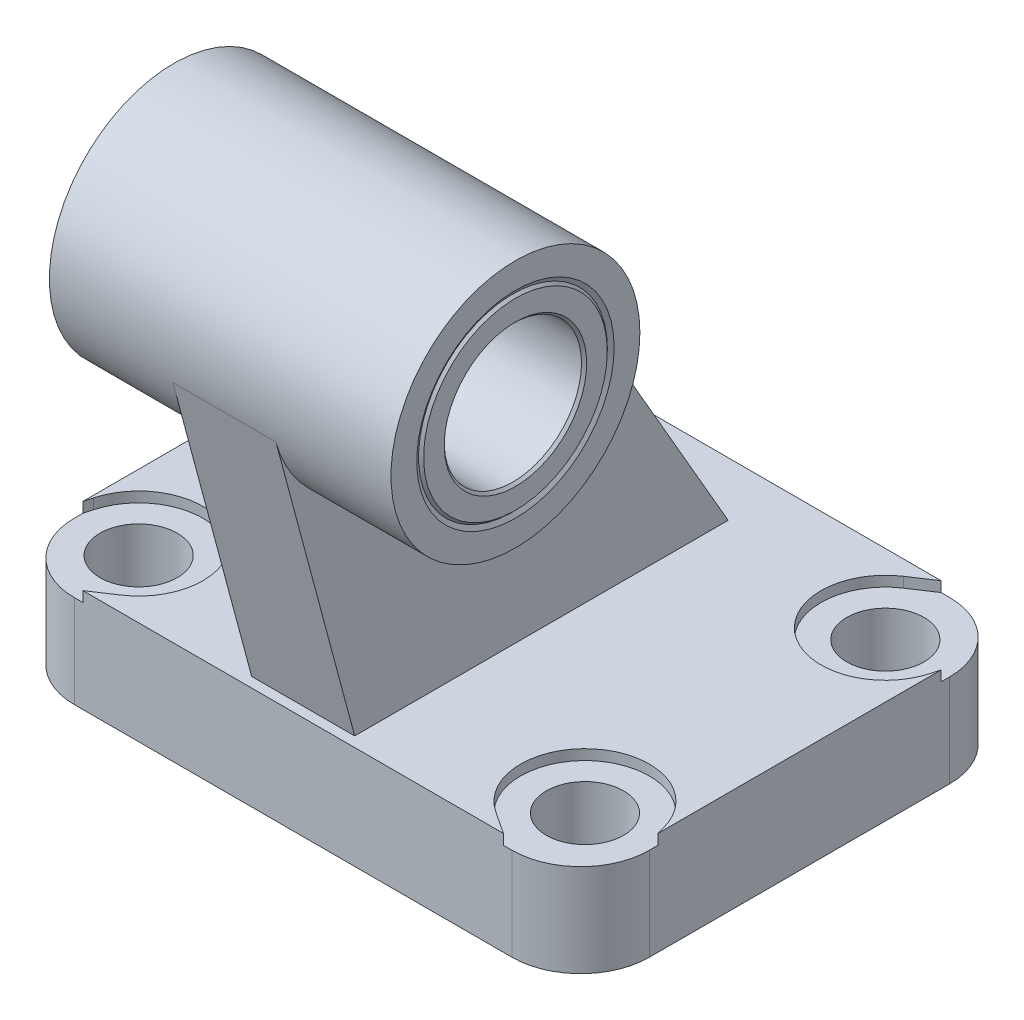
from build123d import *

# Parameters (mm, degrees)
BOSS_EXTRUDE1_DEPTH      = 12
BOSS_EXTRUDE2_DEPTH      = 6
BOSS_EXTRUDE2_DEPTH_BACK = 6
SKETCH3_R                = 14.5
BOSS_EXTRUDE3_DEPTH      = 19.9
BOSS_EXTRUDE3_DEPTH_BACK = 19.9
SKETCH4_W                = 134
SKETCH4_H                = 102
CUT_EXTRUDE1_DEPTH       = 1.2


with BuildPart() as part:
    # Sketch1 → Boss-Extrude1 (new body)
    with BuildSketch(Plane(origin=(0, 0, 0), x_dir=(1, 0, 0), z_dir=(0, 1, 0))):
        with BuildLine():
            Line((-25.5, -25.5), (25.5, -25.5))
            ThreePointArc((25.5, -25.5), (31.156854249, -23.156854249), (33.5, -17.5))
            Line((33.5, -17.5), (33.5, 17.5))
            ThreePointArc((33.5, 17.5), (31.156854249, 23.156854249), (25.5, 25.5))
            Line((25.5, 25.5), (-25.5, 25.5))
            ThreePointArc((-25.5, 25.5), (-31.156854249, 23.156854249), (-33.5, 17.5))
            Line((-33.5, 17.5), (-33.5, -17.5))
            ThreePointArc((-33.5, -17.5), (-31.156854249, -23.156854249), (-25.5, -25.5))
        make_face()
    extrude(amount=BOSS_EXTRUDE1_DEPTH)

    # Sketch2 → Boss-Extrude2 (add, two sides)
    with BuildSketch(Plane(origin=(0, 0, 0), x_dir=(0, 0, -1), z_dir=(1, 0, 0))) as boss_extrude2_sk:
        Polygon((-33.505924481, 46.247123846), (-24.329435304, 12), (19.182468036, 12), (-6.942631645, 57.25), align=None)
    extrude(amount=BOSS_EXTRUDE2_DEPTH)
    extrude(boss_extrude2_sk.sketch, amount=-BOSS_EXTRUDE2_DEPTH_BACK)

    # Sketch3 → Boss-Extrude3 (add, two sides)
    with BuildSketch(Plane(origin=(0, 0, 0), x_dir=(0, 0, -1), z_dir=(1, 0, 0))) as boss_extrude3_sk:
        with Locations((-19.5, 50)):
            Circle(SKETCH3_R)
    extrude(amount=BOSS_EXTRUDE3_DEPTH)
    extrude(boss_extrude3_sk.sketch, amount=-BOSS_EXTRUDE3_DEPTH_BACK)

    # Sketch4 → Cut-Extrude1 (cut)
    with BuildSketch(Plane(origin=(0, 12, 0), x_dir=(1, 0, 0), z_dir=(0, 1, 0))):
        Rectangle(SKETCH4_W, SKETCH4_H)
        with BuildLine():
            Line((-33.5, 16.5), (-33.5, -16.5))
            Line((-33.5, -16.5), (-33.237991266, -15.534934498))
            ThreePointArc((-33.237991266, -15.534934498), (-21.607110594, -11.421141335), (-21.862465515, -23.755462284))
            Line((-21.862465515, -23.755462284), (-24.5, -25.5))
            Line((-24.5, -25.5), (24.5, -25.5))
            Line((24.5, -25.5), (21.862465515, -23.755462284))
            ThreePointArc((21.862465515, -23.755462284), (21.607110594, -11.421141335), (33.237991266, -15.534934498))
            Line((33.237991266, -15.534934498), (33.5, -16.5))
            Line((33.5, -16.5), (33.5, 16.5))
            Line((33.5, 16.5), (33.237991266, 15.534934498))
            ThreePointArc((33.237991266, 15.534934498), (21.607110594, 11.421141335), (21.862465515, 23.755462284))
            Line((21.862465515, 23.755462284), (24.5, 25.5))
            Line((24.5, 25.5), (-24.5, 25.5))
            Line((-24.5, 25.5), (-21.862465515, 23.755462284))
            ThreePointArc((-21.862465515, 23.755462284), (-21.607110594, 11.421141335), (-33.237991266, 15.534934498))
            Line((-33.237991266, 15.534934498), (-33.5, 16.5))
        make_face(mode=Mode.SUBTRACT)
    extrude(amount=-CUT_EXTRUDE1_DEPTH, mode=Mode.SUBTRACT)

    # Sketch5 → Cut-Revolve1 (revolve, cut)
    with BuildSketch(Plane.XY.offset(17.5)):
        Polygon((-26, 0), (-30.5, 0), (-30.5, 10.8), (-33.5, 10.8), (-33.5, 12), (-26, 12), align=None)
    revolve(axis=Axis((-26, 12, 17.5), (0, -1, 0)), mode=Mode.SUBTRACT)

    # Sketch6 → Cut-Revolve2 (revolve, cut)
    with BuildSketch(Plane.XY.offset(-17.5)):
        Polygon((-26, 0), (-30.5, 0), (-30.5, 10.8), (-33.5, 10.8), (-33.5, 12), (-26, 12), align=None)
    revolve(axis=Axis((-26, 12, -17.5), (0, -1, 0)), mode=Mode.SUBTRACT)

    # Sketch7 → Cut-Revolve3 (revolve, cut)
    with BuildSketch(Plane.XY.offset(17.5)):
        Polygon((26, 0), (21.5, 0), (21.5, 10.8), (18.5, 10.8), (18.5, 12), (26, 12), align=None)
    revolve(axis=Axis((26, 12, 17.5), (0, -1, 0)), mode=Mode.SUBTRACT)

    # Sketch8 → Cut-Revolve4 (revolve, cut)
    with BuildSketch(Plane.XY.offset(-17.5)):
        Polygon((26, 0), (21.5, 0), (21.5, 10.8), (18.5, 10.8), (18.5, 12), (26, 12), align=None)
    revolve(axis=Axis((26, 12, -17.5), (0, -1, 0)), mode=Mode.SUBTRACT)

    # Sketch9 → Cut-Revolve5 (revolve, cut)
    with BuildSketch(Plane.XY.offset(19.5)):
        Polygon((-19.9, 50), (-19.9, 61.5), (-19.611324865, 61), (19.611324865, 61), (19.9, 61.5), (19.9, 50), align=None)
    revolve(axis=Axis((19.9, 50, 19.5), (-1, 0, 0)), mode=Mode.SUBTRACT)

    # Sketch10 → Revolve1 (revolve)
    with BuildSketch(Plane.XY.offset(19.5)):
        Polygon((-19.9, 58.3), (-19.6, 58), (19.6, 58), (19.9, 58.3), (19.9, 60.7), (19.6, 61), (-19.6, 61), (-19.9, 60.7), align=None)
    revolve(axis=Axis((19.9, 50, 19.5), (-1, 0, 0)))


solid = part.part
